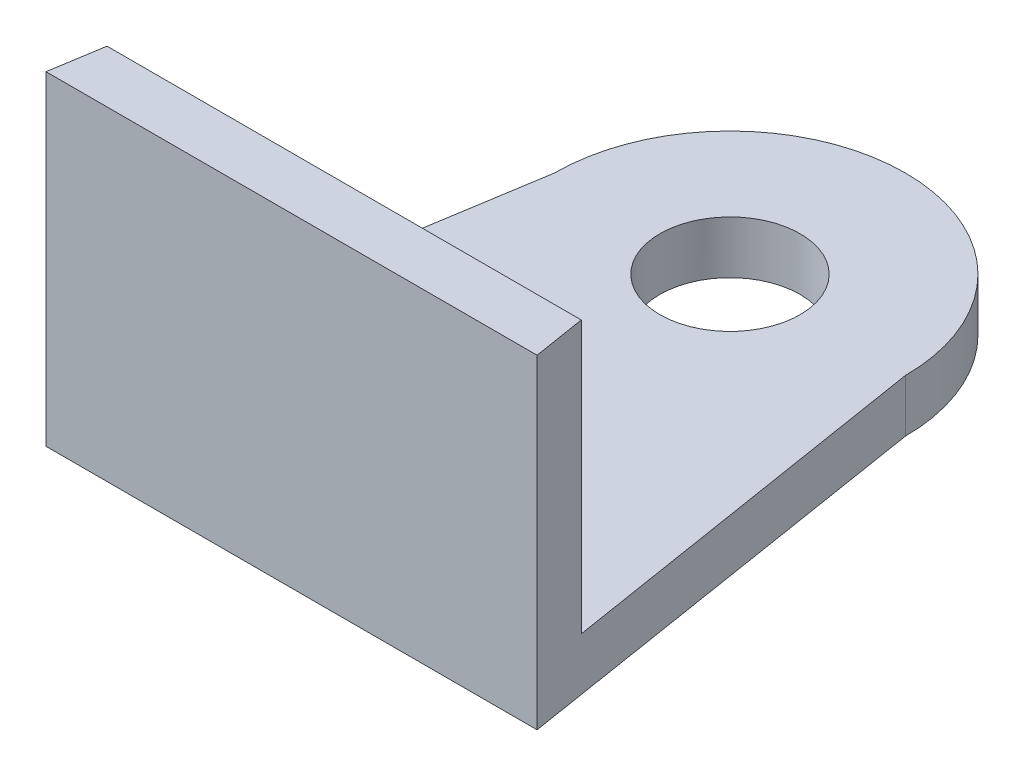
from build123d import *

# Parameters (mm, degrees)
BOSS_EXTRUDE1_DEPTH = 3
SKETCH2_R           = 4
CUT_EXTRUDE1_DEPTH  = 13
BOSS_EXTRUDE2_DEPTH = 15.5


with BuildPart() as part:
    # Sketch1 → Boss-Extrude1 (new body)
    with BuildSketch(Plane(origin=(0, 0, 0), x_dir=(1, 0, 0), z_dir=(0, 1, 0))):
        with BuildLine():
            Line((-10, 0), (-14, -25))
            Line((-14, -25), (14, -25))
            Line((14, -25), (10, 0))
            ThreePointArc((10, 0), (0, 10), (-10, 0))
        make_face()
    extrude(amount=BOSS_EXTRUDE1_DEPTH)

    # Sketch2 → Cut-Extrude1 (cut)
    with BuildSketch(Plane(origin=(0, 3, 0), x_dir=(1, 0, 0), z_dir=(0, 1, 0))):
        Circle(SKETCH2_R)
    extrude(amount=-CUT_EXTRUDE1_DEPTH, mode=Mode.SUBTRACT)

    # Sketch5 → Boss-Extrude2 (add)
    with BuildSketch(Plane(origin=(0, 3, 0), x_dir=(1, 0, 0), z_dir=(0, 1, 0))):
        Polygon((-13.52, -22), (13.52, -22), (14, -25), (-14, -25), align=None)
    extrude(amount=BOSS_EXTRUDE2_DEPTH)


solid = part.part
